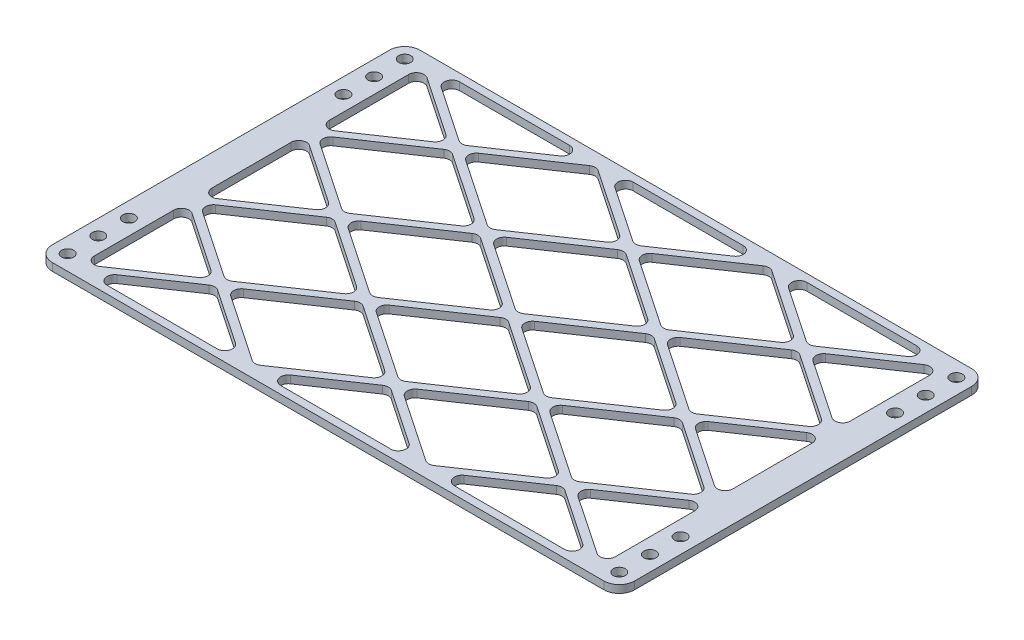
from build123d import *

# Parameters (mm, degrees)
SKETCH1_W            = 241.3
SKETCH1_H            = 152.4
SKETCH1_R            = 2.4892
BOSS_EXTRUDE5_DEPTH  = 3.175
CUT_EXTRUDE7_DEPTH   = 32.131
LPATTERN3_COUNT      = 3
LPATTERN3_PITCH      = 71.966666667
LPATTERN3_COUNT_DIR2 = 3
LPATTERN3_PITCH_DIR2 = 48.683333333
FILLET2_R            = 3.175
FILLET3_R            = 6.35
SKETCH2_R            = 2.4892
CUT_EXTRUDE8_DEPTH   = 286.414664348


with BuildPart() as part:
    # Sketch1 → Boss-Extrude5 (new body)
    with BuildSketch(Plane(origin=(0, 0, 0), x_dir=(1, 0, 0), z_dir=(0, 1, 0))):
        with Locations((120.65, 76.2)):
            Rectangle(SKETCH1_W, SKETCH1_H)
        with Locations((6.35, 6.35)):
            Circle(SKETCH1_R, mode=Mode.SUBTRACT)
        with Locations((6.35, 146.05)):
            Circle(SKETCH1_R, mode=Mode.SUBTRACT)
    extrude(amount=BOSS_EXTRUDE5_DEPTH)

    # Sketch1_6 → Cut-Extrude7 (cut)
    with BuildSketch(Plane(origin=(0, 0, 0), x_dir=(1, 0, 0), z_dir=(0, 1, 0))):
        Polygon((45.850077115, 124.883333333), (12.7, 147.3083855), (12.7, 102.458281167), align=None)
        Polygon((81.833410449, 149.225), (15.533256218, 149.225), (48.683333333, 126.799947834), align=None)
        Polygon((81.833410449, 100.541666667), (48.683333333, 122.966718833), (15.533256218, 100.541666667), align=None)
        Polygon((51.516589551, 124.883333333), (84.666666667, 102.458281167), (84.666666667, 147.3083855), align=None)
    cut_extrude7 = extrude(amount=CUT_EXTRUDE7_DEPTH, mode=Mode.SUBTRACT)

    # LPattern3: Cut-Extrude7 3 × 3
    with Locations(*[(i * LPATTERN3_PITCH, 0, j * LPATTERN3_PITCH_DIR2) for i in range(LPATTERN3_COUNT) for j in range(LPATTERN3_COUNT_DIR2) if (i, j) != (0, 0)]):
        add(cut_extrude7, mode=Mode.SUBTRACT)

    # Fillet2
    fillet2_edges = [part.edges().sort_by_distance(p)[0] for p in [
        (156.633333333, 1.5875, -49.941718833),
        (123.483256218, 1.5875, -27.516666667),
        (156.633333333, 1.5875, -5.0916145),
        (189.783410449, 1.5875, -27.516666667),
        (84.666666667, 1.5875, -49.941718833),
        (51.516589551, 1.5875, -27.516666667),
        (84.666666667, 1.5875, -5.0916145),
        (117.816743782, 1.5875, -27.516666667),
        (45.850077115, 1.5875, -27.516666667),
        (12.7, 1.5875, -49.941718833),
        (12.7, 1.5875, -5.0916145),
        (156.633333333, 1.5875, -147.3083855),
        (123.483256218, 1.5875, -124.883333333),
        (156.633333333, 1.5875, -102.458281167),
        (189.783410449, 1.5875, -124.883333333),
        (45.850077115, 1.5875, -76.2),
        (12.7, 1.5875, -98.625052166),
        (12.7, 1.5875, -53.774947834),
        (84.666666667, 1.5875, -98.625052166),
        (51.516589551, 1.5875, -76.2),
        (84.666666667, 1.5875, -53.774947834),
        (117.816743782, 1.5875, -76.2),
        (156.633333333, 1.5875, -98.625052166),
        (123.483256218, 1.5875, -76.2),
        (156.633333333, 1.5875, -53.774947834),
        (189.783410449, 1.5875, -76.2),
        (84.666666667, 1.5875, -147.3083855),
        (51.516589551, 1.5875, -124.883333333),
        (84.666666667, 1.5875, -102.458281167),
        (117.816743782, 1.5875, -124.883333333),
        (192.616666667, 1.5875, -25.600052166),
        (159.466589551, 1.5875, -3.175),
        (225.766743782, 1.5875, -3.175),
        (120.65, 1.5875, -25.600052166),
        (87.499922885, 1.5875, -3.175),
        (153.800077115, 1.5875, -3.175),
        (48.683333333, 1.5875, -25.600052166),
        (15.533256218, 1.5875, -3.175),
        (81.833410449, 1.5875, -3.175),
        (159.466589551, 1.5875, -100.541666667),
        (192.616666667, 1.5875, -78.1166145),
        (225.766743782, 1.5875, -100.541666667),
        (192.616666667, 1.5875, -122.966718833),
        (15.533256218, 1.5875, -51.858333333),
        (48.683333333, 1.5875, -29.433281167),
        (81.833410449, 1.5875, -51.858333333),
        (48.683333333, 1.5875, -74.2833855),
        (87.499922885, 1.5875, -51.858333333),
        (120.65, 1.5875, -29.433281167),
        (153.800077115, 1.5875, -51.858333333),
        (120.65, 1.5875, -74.2833855),
        (159.466589551, 1.5875, -51.858333333),
        (192.616666667, 1.5875, -29.433281167),
        (225.766743782, 1.5875, -51.858333333),
        (192.616666667, 1.5875, -74.2833855),
        (87.499922885, 1.5875, -100.541666667),
        (120.65, 1.5875, -78.1166145),
        (153.800077115, 1.5875, -100.541666667),
        (120.65, 1.5875, -122.966718833),
        (45.850077115, 1.5875, -124.883333333),
        (12.7, 1.5875, -147.3083855),
        (12.7, 1.5875, -102.458281167),
        (48.683333333, 1.5875, -126.799947834),
        (15.533256218, 1.5875, -149.225),
        (120.65, 1.5875, -126.799947834),
        (153.800077115, 1.5875, -149.225),
        (87.499922885, 1.5875, -149.225),
        (48.683333333, 1.5875, -78.1166145),
        (81.833410449, 1.5875, -100.541666667),
        (48.683333333, 1.5875, -122.966718833),
        (15.533256218, 1.5875, -100.541666667),
        (192.616666667, 1.5875, -126.799947834),
        (225.766743782, 1.5875, -149.225),
        (159.466589551, 1.5875, -149.225),
        (195.449922885, 1.5875, -76.2),
        (228.6, 1.5875, -53.774947834),
        (228.6, 1.5875, -98.625052166),
        (195.449922885, 1.5875, -124.883333333),
        (228.6, 1.5875, -102.458281167),
        (228.6, 1.5875, -147.3083855),
        (195.449922885, 1.5875, -27.516666667),
        (228.6, 1.5875, -5.0916145),
        (228.6, 1.5875, -49.941718833),
        (81.833410449, 1.5875, -149.225),
    ]]
    fillet(fillet2_edges, radius=FILLET2_R)

    # Fillet3
    fillet3_edges = [part.edges().sort_by_distance(p)[0] for p in [
        (241.3, 1.5875, 0),
        (0, 1.5875, 0),
        (241.3, 1.5875, -152.4),
        (0, 1.5875, -152.4),
    ]]
    fillet(fillet3_edges, radius=FILLET3_R)

    # Sketch2 → Cut-Extrude8 (cut, through all)
    with BuildSketch(Plane(origin=(0, 3.175, 0), x_dir=(1, 0, 0), z_dir=(0, 1, 0))):
        with Locations((234.95, 146.05)):
            Circle(SKETCH2_R)
        with Locations((234.95, 133.35)):
            Circle(SKETCH2_R)
        with Locations((234.95, 120.65)):
            Circle(SKETCH2_R)
        with Locations((234.95, 31.75)):
            Circle(SKETCH2_R)
        with Locations((234.95, 19.05)):
            Circle(SKETCH2_R)
        with Locations((234.95, 6.35)):
            Circle(SKETCH2_R)
        with Locations((6.35, 133.35)):
            Circle(SKETCH2_R)
        with Locations((6.35, 120.65)):
            Circle(SKETCH2_R)
        with Locations((6.35, 31.75)):
            Circle(SKETCH2_R)
        with Locations((6.35, 19.05)):
            Circle(SKETCH2_R)
    extrude(amount=-CUT_EXTRUDE8_DEPTH, mode=Mode.SUBTRACT)


solid = part.part
